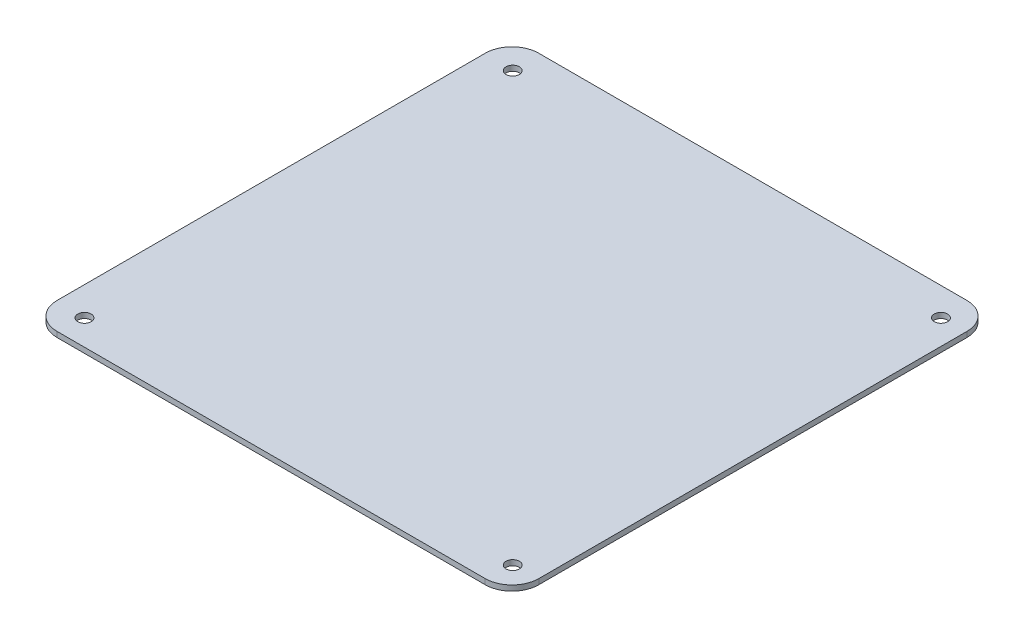
from build123d import *

# Parameters (mm, degrees)
SKETCH1_W           = 180
SKETCH1_H           = 180
SKETCH1_R           = 2.5
BOSS_EXTRUDE1_DEPTH = 2
FILLET1_R           = 10


with BuildPart() as part:
    # Sketch1 → Boss-Extrude1 (new body)
    with BuildSketch(Plane(origin=(0, 0, 0), x_dir=(1, 0, 0), z_dir=(0, 1, 0))):
        with Locations((-11.746430923, -29.117647059)):
            Rectangle(SKETCH1_W, SKETCH1_H)
        with Locations((-90.985623289, 50.387970606)):
            Circle(SKETCH1_R, mode=Mode.SUBTRACT)
        with Locations((69.014376711, 50.387970606)):
            Circle(SKETCH1_R, mode=Mode.SUBTRACT)
        with Locations((-90.985623289, -109.612029394)):
            Circle(SKETCH1_R, mode=Mode.SUBTRACT)
        with Locations((69.014376711, -109.612029394)):
            Circle(SKETCH1_R, mode=Mode.SUBTRACT)
    extrude(amount=BOSS_EXTRUDE1_DEPTH)

    # Fillet1
    fillet1_edges = [part.edges().sort_by_distance(p)[0] for p in [
        (-101.746430923, 1, -60.882352941),
        (78.253569077, 1, -60.882352941),
        (78.253569077, 1, 119.117647059),
        (-101.746430923, 1, 119.117647059),
    ]]
    fillet(fillet1_edges, radius=FILLET1_R)


solid = part.part
